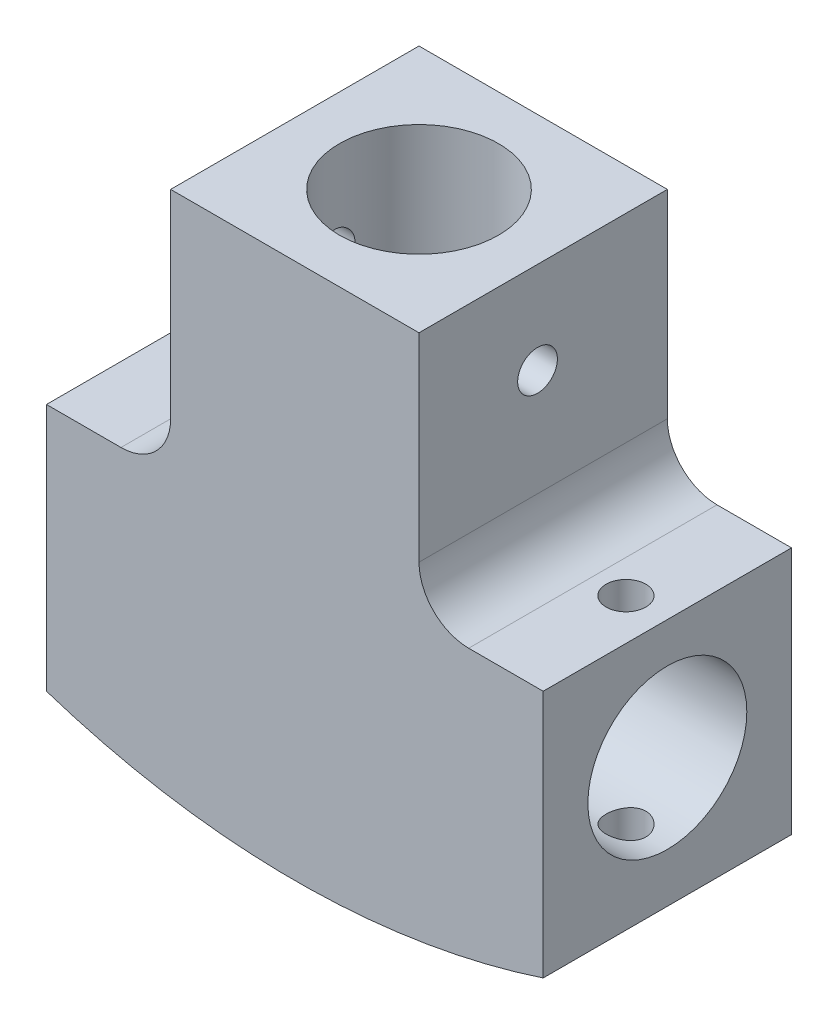
from build123d import *

# Parameters (mm, degrees)
CROQUIS2_W                 = 50
CROQUIS2_H                 = 25
SALIENTE_EXTRUIR2_DEPTH    = 25
CROQUIS9_W                 = 25
CROQUIS9_H                 = 25
SALIENTE_EXTRUIR3_DEPTH    = 50
CROQUIS10_R                = 8
CORTAR_EXTRUIR2_DEPTH      = 43
CORTAR_EXTRUIR2_DEPTH_BACK = 49
CROQUIS11_R                = 8
CORTAR_EXTRUIR3_DEPTH      = 37.5
REDONDEO1_R                = 5
SALIENTE_EXTRUIR4_DEPTH    = 12.5
CROQUIS15_R                = 2
CORTAR_EXTRUIR4_DEPTH      = 33
CROQUIS16_R                = 2
CORTAR_EXTRUIR5_DEPTH      = 33


with BuildPart() as part:
    # Croquis2 → Saliente-Extruir2 (new body)
    with BuildSketch(Plane(origin=(0, 0, 0), x_dir=(1, 0, 0), z_dir=(0, 1, 0))):
        Rectangle(CROQUIS2_W, CROQUIS2_H)
    extrude(amount=SALIENTE_EXTRUIR2_DEPTH)

    # Croquis9 → Saliente-Extruir3 (add)
    with BuildSketch(Plane(origin=(0, 0, 0), x_dir=(1, 0, 0), z_dir=(0, 1, 0))):
        Rectangle(CROQUIS9_W, CROQUIS9_H)
    extrude(amount=SALIENTE_EXTRUIR3_DEPTH)

    # Croquis10 → Cortar-Extruir2 (cut, two sides)
    with BuildSketch(Plane(origin=(0, 0, 0), x_dir=(0, 0, -1), z_dir=(1, 0, 0))) as cortar_extruir2_sk:
        with Locations((0, 12.957262023)):
            Circle(CROQUIS10_R)
    extrude(amount=CORTAR_EXTRUIR2_DEPTH, mode=Mode.SUBTRACT)
    extrude(cortar_extruir2_sk.sketch, amount=-CORTAR_EXTRUIR2_DEPTH_BACK, mode=Mode.SUBTRACT)

    # Croquis11 → Cortar-Extruir3 (cut, symmetric)
    with BuildSketch(Plane(origin=(0, 50, 0), x_dir=(1, 0, 0), z_dir=(0, 1, 0))):
        Circle(CROQUIS11_R)
    extrude(amount=CORTAR_EXTRUIR3_DEPTH, both=True, mode=Mode.SUBTRACT)

    # Redondeo1
    redondeo1_edges = [part.edges().sort_by_distance(p)[0] for p in [
        (12.5, 25, 0),
        (-12.5, 25, 0),
    ]]
    fillet(redondeo1_edges, radius=REDONDEO1_R)

    # Croquis13 → Saliente-Extruir4 (add, symmetric)
    with BuildSketch(Plane.XY):
        with BuildLine():
            Line((-25, 0), (25, 0))
            ThreePointArc((25, 0), (0, -4.006579232), (-25, 0))
        make_face()
    extrude(amount=SALIENTE_EXTRUIR4_DEPTH, both=True)

    # Croquis15 → Cortar-Extruir4 (cut)
    with BuildSketch(Plane.ZY.offset(12.5)):
        with Locations((0.568263939, 40.759281312)):
            Circle(CROQUIS15_R)
    extrude(amount=-CORTAR_EXTRUIR4_DEPTH, mode=Mode.SUBTRACT)

    # Croquis16 → Cortar-Extruir5 (cut)
    with BuildSketch(Plane(origin=(0, 25, 0), x_dir=(1, 0, 0), z_dir=(0, 1, 0))):
        with Locations((20.833740283, 0)):
            Circle(CROQUIS16_R)
    cortar_extruir5 = extrude(amount=-CORTAR_EXTRUIR5_DEPTH, mode=Mode.SUBTRACT)

    # Simetría1: Cortar-Extruir5 across plane
    add(cortar_extruir5.mirror(Plane(origin=(0, 0, 0), x_dir=(0, 0, 1), z_dir=(1, 0, 0))), mode=Mode.SUBTRACT)


solid = part.part
